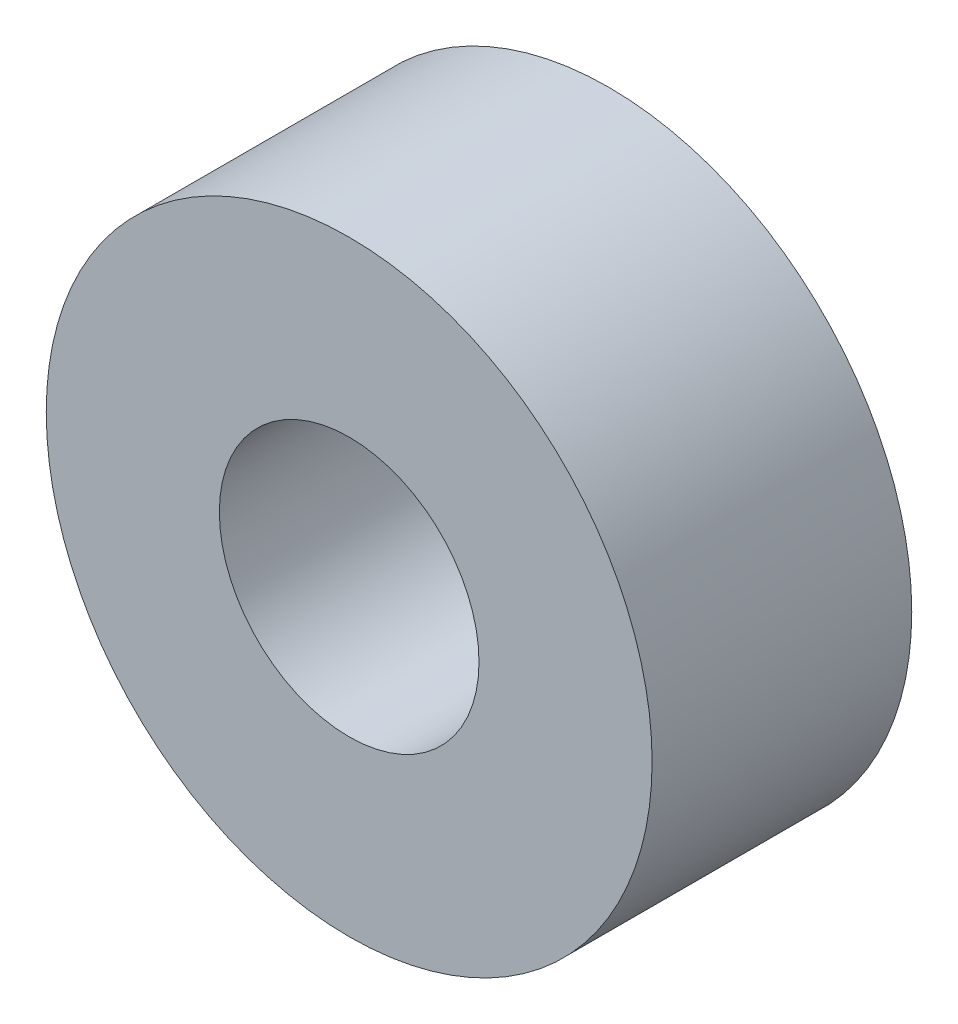
from build123d import *

# Parameters (mm, degrees)
SKETCH_1_R      = 3.5
SKETCH_1_R_2    = 1.5
EXTRUDE_1_DEPTH = 3


with BuildPart() as part:
    # 草图1 → 凸台-拉伸1 (new body)
    with BuildSketch(Plane.XY):
        Circle(SKETCH_1_R)
        Circle(SKETCH_1_R_2, mode=Mode.SUBTRACT)
    extrude(amount=EXTRUDE_1_DEPTH)


solid = part.part
